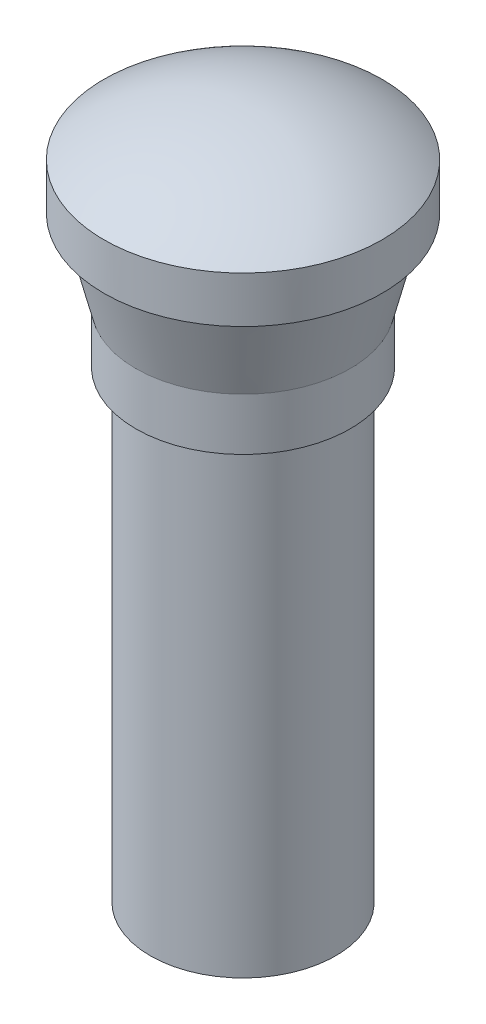
from build123d import *


with BuildPart() as part:
    # Esquisse1 → Révolution1 (revolve)
    with BuildSketch(Plane.XY):
        with BuildLine():
            Line((0, 0), (8, 0))
            Line((8, 0), (8, 40))
            Line((8, 40), (9.25, 40))
            Line((9.25, 40), (9.25, 44.5))
            Line((9.25, 44.5), (11, 51.5))
            Line((11, 51.5), (12, 51.5))
            Line((12, 51.5), (12, 55.5))
            ThreePointArc((12, 55.5), (6.32455532, 58.473665961), (0, 59.5))
            Line((0, 59.5), (0, 0))
        make_face()
    revolve(axis=Axis((0, 0, 0), (0, 1, 0)))


solid = part.part
